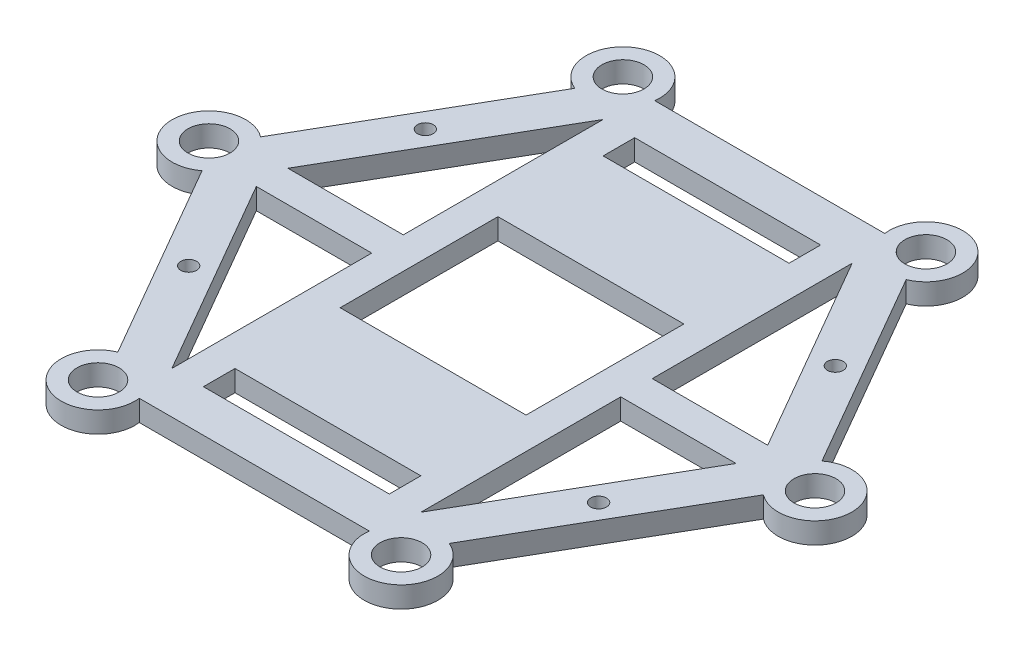
from build123d import *

# Parameters (mm, degrees)
SKETCH_1_R          = 4
SKETCH_1_R_2        = 1.5
SKETCH_1_W          = 35.342722074
SKETCH_1_H          = 6
SKETCH_1_H_2        = 30
EXTRUDE_1_DEPTH     = 4
CUT_EXTRUDE_START   = -2
SKETCH_2_R          = 7
CUT_EXTRUDE_1_DEPTH = 1.1


with BuildPart() as part:
    # 草图1 → 凸台-拉伸1 (new body)
    with BuildSketch(Plane(origin=(0, 0, 0), x_dir=(1, 0, 0), z_dir=(0, 1, 0))):
        with BuildLine():
            ThreePointArc((-21.862962012, 49), (-32.305762114, 55.955221358), (-31.503763779, 43.433880504))
            Line((-31.503763779, 43.433880504), (-53.366725791, 5.566119496))
            ThreePointArc((-53.366725791, 5.566119496), (-64.611524227, 0), (-53.366725791, -5.566119496))
            Line((-53.366725791, -5.566119496), (-31.503763779, -43.433880504))
            ThreePointArc((-31.503763779, -43.433880504), (-32.305762114, -55.955221358), (-21.862962012, -49))
            Line((-21.862962012, -49), (21.862962012, -49))
            ThreePointArc((21.862962012, -49), (32.305762114, -55.955221358), (31.503763779, -43.433880504))
            Line((31.503763779, -43.433880504), (53.366725791, -5.566119496))
            ThreePointArc((53.366725791, -5.566119496), (64.611524227, 0), (53.366725791, 5.566119496))
            Line((53.366725791, 5.566119496), (31.503763779, 43.433880504))
            ThreePointArc((31.503763779, 43.433880504), (32.305762114, 55.955221358), (21.862962012, 49))
            Line((21.862962012, 49), (-21.862962012, 49))
        make_face()
        with Locations((-28.805762114, 49.893043531)):
            Circle(SKETCH_1_R, mode=Mode.SUBTRACT)
        with Locations((28.805762114, -49.893043531)):
            Circle(SKETCH_1_R, mode=Mode.SUBTRACT)
        with Locations((-28.805762114, -49.893043531)):
            Circle(SKETCH_1_R, mode=Mode.SUBTRACT)
        with Locations((-57.611524227, 0)):
            Circle(SKETCH_1_R, mode=Mode.SUBTRACT)
        with Locations((38.97114317, 22.5)):
            Circle(SKETCH_1_R_2, mode=Mode.SUBTRACT)
        with Locations((-38.97114317, -22.5)):
            Circle(SKETCH_1_R_2, mode=Mode.SUBTRACT)
        with Locations((0, 38)):
            Rectangle(SKETCH_1_W, SKETCH_1_H, mode=Mode.SUBTRACT)
        Rectangle(SKETCH_1_W, SKETCH_1_H_2, mode=Mode.SUBTRACT)
        with Locations((0, -38)):
            Rectangle(SKETCH_1_W, SKETCH_1_H, mode=Mode.SUBTRACT)
        Polygon((23.671361037, 41), (45.610671266, 3), (23.671361037, 3), align=None, mode=Mode.SUBTRACT)
        Polygon((45.610671266, -3), (23.671361037, -41), (23.671361037, -3), align=None, mode=Mode.SUBTRACT)
        Polygon((-23.671361037, -41), (-45.610671266, -3), (-23.671361037, -3), align=None, mode=Mode.SUBTRACT)
        Polygon((-45.610671266, 3), (-23.671361037, 41), (-23.671361037, 3), align=None, mode=Mode.SUBTRACT)
        with Locations((38.97114317, -22.5)):
            Circle(SKETCH_1_R_2, mode=Mode.SUBTRACT)
        with Locations((-38.97114317, 22.5)):
            Circle(SKETCH_1_R_2, mode=Mode.SUBTRACT)
        with Locations((28.805762114, 49.893043531)):
            Circle(SKETCH_1_R, mode=Mode.SUBTRACT)
        with Locations((57.611524227, 0)):
            Circle(SKETCH_1_R, mode=Mode.SUBTRACT)
    extrude(amount=EXTRUDE_1_DEPTH)

    # 草图2 → 切除-拉伸1 (cut)
    with BuildSketch(Plane(origin=(0, 4, 0), x_dir=(1, 0, 0), z_dir=(0, 1, 0)).offset(CUT_EXTRUDE_START)):
        with Locations((0, 25)):
            Circle(SKETCH_2_R)
        with Locations((-0.013100305, -25.004400745)):
            Circle(SKETCH_2_R)
    extrude(amount=CUT_EXTRUDE_1_DEPTH, mode=Mode.SUBTRACT)


solid = part.part
